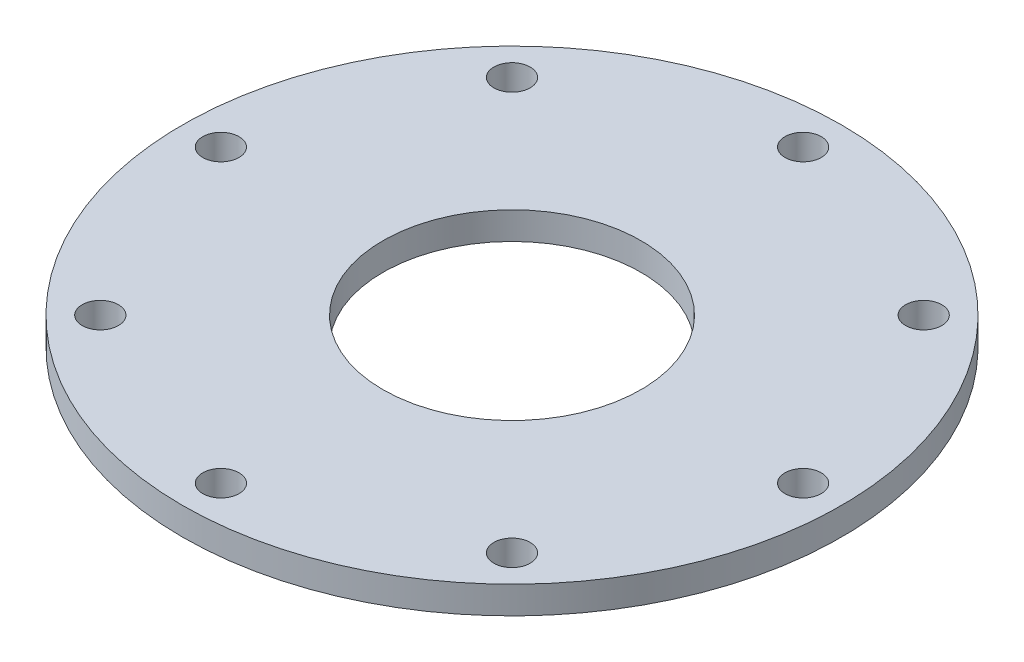
from build123d import *

# Parameters (mm, degrees)
SKETCH1_R            = 60
SKETCH1_R_2          = 23.5
BOSS_EXTRUDE1_DEPTH  = 5
M6_CLEARANCE_HOLE1_D = 6.6


with BuildPart() as part:
    # Sketch1 → Boss-Extrude1 (new body)
    with BuildSketch(Plane(origin=(0, 0, 0), x_dir=(1, 0, 0), z_dir=(0, 1, 0))):
        Circle(SKETCH1_R)
        Circle(SKETCH1_R_2, mode=Mode.SUBTRACT)
    extrude(amount=BOSS_EXTRUDE1_DEPTH)

    # M6 Clearance Hole1 (through all)
    with Locations(Plane(origin=(0, 5, 0), x_dir=(1, 0, 0), z_dir=(0, 1, 0))):
        with Locations((-37.476659403, 37.476659403), (0, 53), (37.476659403, 37.476659403), (53, 0), (37.476659403, -37.476659403), (0, -53), (-37.476659403, -37.476659403), (-53, 0)):
            Hole(M6_CLEARANCE_HOLE1_D / 2)


solid = part.part
